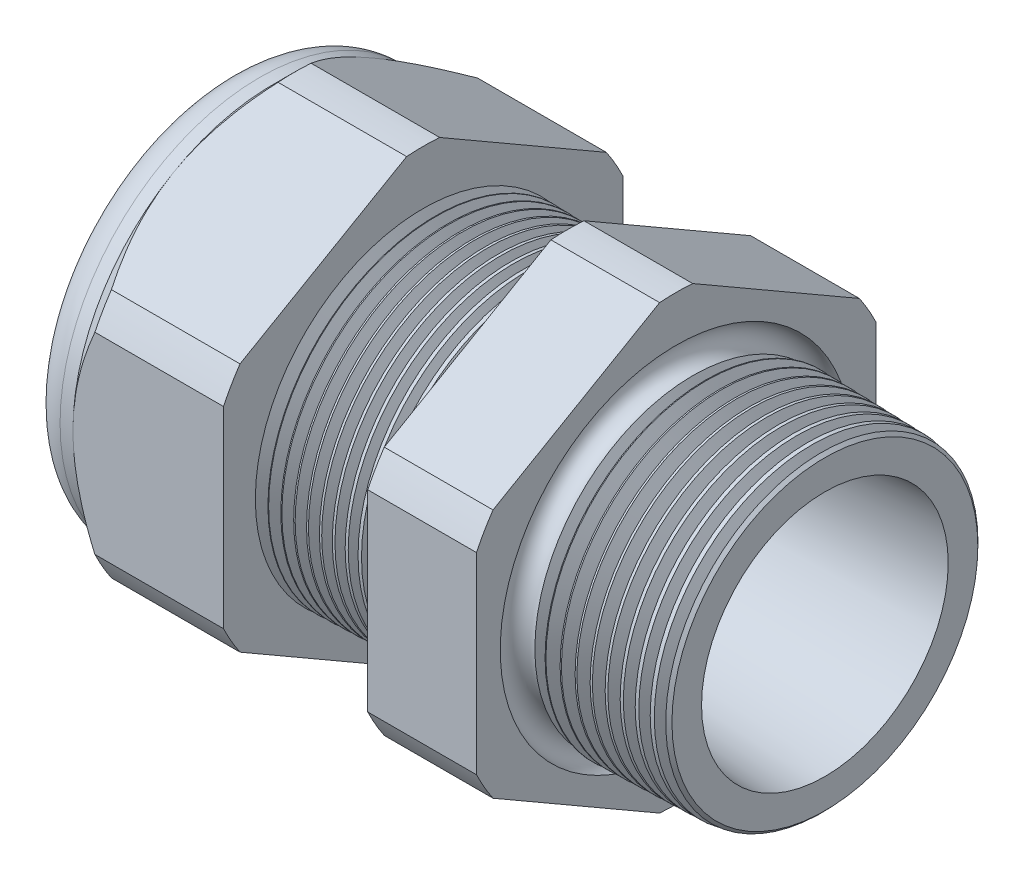
from build123d import *

# Parameters (mm, degrees)
SKETCH12_OUTSIDE_W = 65.04
SKETCH12_OUTSIDE_H = 65.04
CUT_EXTRUDE2_DEPTH = 34.014
FILLET4_R          = 2.032
SKETCH19_OUTSIDE_W = 39.986
SKETCH19_OUTSIDE_H = 42.612
SKETCH19_OUTSIDE_R = 11.938
CUT_EXTRUDE3_DEPTH = 1.999996
CUT_EXTRUDE3_DRAFT = -45
CHAMFER1_SIZE      = 0.260919487
CHAMFER1_SIZE2     = 0.254
SKETCH21_R         = 5.969
PLUG_DEPTH         = 6.35
SKETCH22_R         = 5.715
CUT_EXTRUDE4_DEPTH = 0.508
LPATTERN1_COUNT    = 11
LPATTERN1_PITCH    = 0.762
LPATTERN2_COUNT    = 10
LPATTERN2_PITCH    = 0.889
SKETCH32_R         = 0.889


with BuildPart() as part:
    # Sketch10 → Revolve2 (revolve)
    with BuildSketch(Plane.XY, mode=Mode.PRIVATE) as revolve2_sk:
        Polygon((-34.798, 5.969), (-22.998, 5.969), (1.016, 7.372171279), (1.016, 9.404171279), (-7.874, 9.636964122), (-7.874, 23.876), (-14.374, 23.876), (-14.374, 9.807172612), (-22.998, 10.033), (-22.998, 23.876), (-31.998, 23.876), (-31.998, 11.938), (-34.798, 11.938), align=None)
    revolve(revolve2_sk.sketch.rotate(Axis((0, 0, 0), (-1, 0, 0)), 90), axis=Axis((0, 0, 0), (-1, 0, 0)))  # turned: the seam where the file's is

    # Sketch12 outside → Cut-Extrude2 (cut, through all)
    with BuildSketch(Plane.ZY.offset(31.998)):
        Rectangle(SKETCH12_OUTSIDE_W, SKETCH12_OUTSIDE_H)
        with BuildLine():
            Line((-0.98819228, 13.214281948), (-10.94980772, 7.462940592))
            ThreePointArc((-10.94980772, 7.462940592), (-11.47585851, 6.62559), (-11.938, 5.751341356))
            Line((-11.938, 5.751341356), (-11.938, -5.751341356))
            ThreePointArc((-11.938, -5.751341356), (-11.47585851, -6.62559), (-10.94980772, -7.462940592))
            Line((-10.94980772, -7.462940592), (-0.98819228, -13.214281948))
            ThreePointArc((-0.98819228, -13.214281948), (0, -13.25118), (0.98819228, -13.214281948))
            Line((0.98819228, -13.214281948), (10.94980772, -7.462940592))
            ThreePointArc((10.94980772, -7.462940592), (11.47585851, -6.62559), (11.938, -5.751341356))
            Line((11.938, -5.751341356), (11.938, 5.751341356))
            ThreePointArc((11.938, 5.751341356), (11.47585851, 6.62559), (10.94980772, 7.462940592))
            Line((10.94980772, 7.462940592), (0.98819228, 13.214281948))
            ThreePointArc((0.98819228, 13.214281948), (0, 13.25118), (-0.98819228, 13.214281948))
        make_face(mode=Mode.SUBTRACT)
    extrude(amount=-CUT_EXTRUDE2_DEPTH, mode=Mode.SUBTRACT)

    # Fillet4
    fillet4_edges = [part.edges().sort_by_distance(p)[0] for p in [
        (-34.798, 0, 11.938),
    ]]
    fillet(fillet4_edges, radius=FILLET4_R)


with BuildPart() as cut_extrude3_tool:
    # Sketch19 outside → Cut-Extrude3 (with draft: the straight prism first)
    with BuildSketch(Plane.ZY.offset(31.998)):
        Rectangle(SKETCH19_OUTSIDE_W, SKETCH19_OUTSIDE_H)
        Circle(SKETCH19_OUTSIDE_R, mode=Mode.SUBTRACT)
    extrude(amount=-CUT_EXTRUDE3_DEPTH)
    # Cut-Extrude3: the draft: its side faces are tilted about the plane it starts from
    cut_extrude3_sides = [cut_extrude3_tool.faces().sort_by_distance(p)[0] for p in [
        (-30.998002, -21.306, 0),
        (-30.998002, 0, 19.993),
        (-30.998002, 21.306, 0),
        (-30.998002, 0, -19.993),
        (-30.998002, 0, -11.938),
    ]]
    draft(cut_extrude3_sides, Plane.ZY.offset(31.998), CUT_EXTRUDE3_DRAFT)


with BuildPart() as part_1:
    add(part.part)

    # Cut-Extrude3: cut by cut_extrude3_tool
    add(cut_extrude3_tool.part, mode=Mode.SUBTRACT)

    # Chamfer1
    chamfer1_edges = [part_1.edges().sort_by_distance(p)[0] for p in [
        (1.016, 0, 9.404171279),
    ]]
    chamfer1_side = [part_1.faces().sort_by_distance(p)[0] for p in [
        (1.016, 0, 7.638161411),
    ]]
    chamfer(chamfer1_edges, length=CHAMFER1_SIZE, length2=CHAMFER1_SIZE2, reference=chamfer1_side[0])

    # Sketch29 → Cut-Revolve1 (revolve, cut)
    with BuildSketch(Plane.XY, mode=Mode.PRIVATE) as cut_revolve1_sk:
        Polygon((-22.998, 10.033), (-22.265016419, 10.013806149), (-22.648130572, 9.388620673), align=None)
    cut_revolve1 = revolve(cut_revolve1_sk.sketch.rotate(Axis((0, 0, 0), (-1, 0, 0)), 90), axis=Axis((0, 0, 0), (-1, 0, 0)), mode=Mode.SUBTRACT)  # turned: the seam where the file's is

    # LPattern1: Cut-Revolve1 ×11
    with Locations(*[(i * LPATTERN1_PITCH, 0, 0) for i in range(1, LPATTERN1_COUNT)]):
        add(cut_revolve1, mode=Mode.SUBTRACT)

    # Sketch30 → Cut-Revolve2 (revolve, cut)
    with BuildSketch(Plane.XY, mode=Mode.PRIVATE) as cut_revolve2_sk:
        Polygon((-7.874, 9.636964122), (-6.994419703, 9.613931502), (-7.454156686, 8.86370893), align=None)
    cut_revolve2 = revolve(cut_revolve2_sk.sketch.rotate(Axis((0, 0, 0), (-1, 0, 0)), 270), axis=Axis((0, 0, 0), (-1, 0, 0)), mode=Mode.SUBTRACT)  # turned: the seam where the file's is

    # LPattern2: Cut-Revolve2 ×10
    with Locations(*[(i * LPATTERN2_PITCH, 0, 0) for i in range(1, LPATTERN2_COUNT)]):
        add(cut_revolve2, mode=Mode.SUBTRACT)

    # Sketch32 → Cut-Revolve3 (revolve, cut)
    with BuildSketch(Plane.XY, mode=Mode.PRIVATE) as cut_revolve3_sk:
        with Locations((-7.747, 9.636964122)):
            Circle(SKETCH32_R)
    revolve(cut_revolve3_sk.sketch.rotate(Axis((0, 0, 0), (-1, 0, 0)), 270), axis=Axis((0, 0, 0), (-1, 0, 0)), mode=Mode.SUBTRACT)  # turned: the seam where the file's is


with BuildPart() as body_2:
    # Sketch21 → plug (new body)
    with BuildSketch(Plane.ZY.offset(34.798)):
        Circle(SKETCH21_R)
    extrude(amount=-PLUG_DEPTH)

    # Sketch22 → Cut-Extrude4 (cut)
    with BuildSketch(Plane.ZY.offset(34.798)):
        Circle(SKETCH22_R)
    extrude(amount=-CUT_EXTRUDE4_DEPTH, mode=Mode.SUBTRACT)


solid = Compound([part_1.part, body_2.part])
